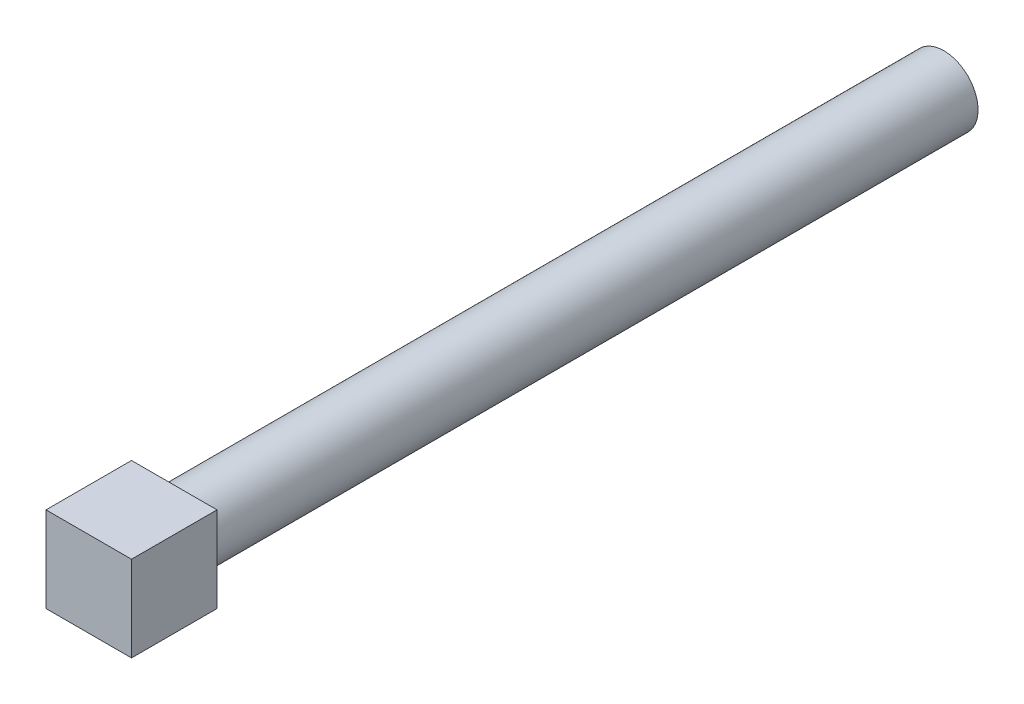
from build123d import *

# Parameters (mm, degrees)
SKETCH_1_W      = 10
SKETCH_1_H      = 10
EXTRUDE_1_DEPTH = 10
SKETCH_2_R      = 4
EXTRUDE_2_DEPTH = 90


with BuildPart() as part:
    # 草图1 → 凸台-拉伸1 (new body)
    with BuildSketch(Plane.XY):
        Rectangle(SKETCH_1_W, SKETCH_1_H)
    extrude(amount=EXTRUDE_1_DEPTH)

    # 草图2 → 凸台-拉伸2 (add)
    with BuildSketch(Plane(origin=(0, 0, 0), x_dir=(-1, 0, 0), z_dir=(0, 0, -1))):
        Circle(SKETCH_2_R)
    extrude(amount=EXTRUDE_2_DEPTH)


solid = part.part
